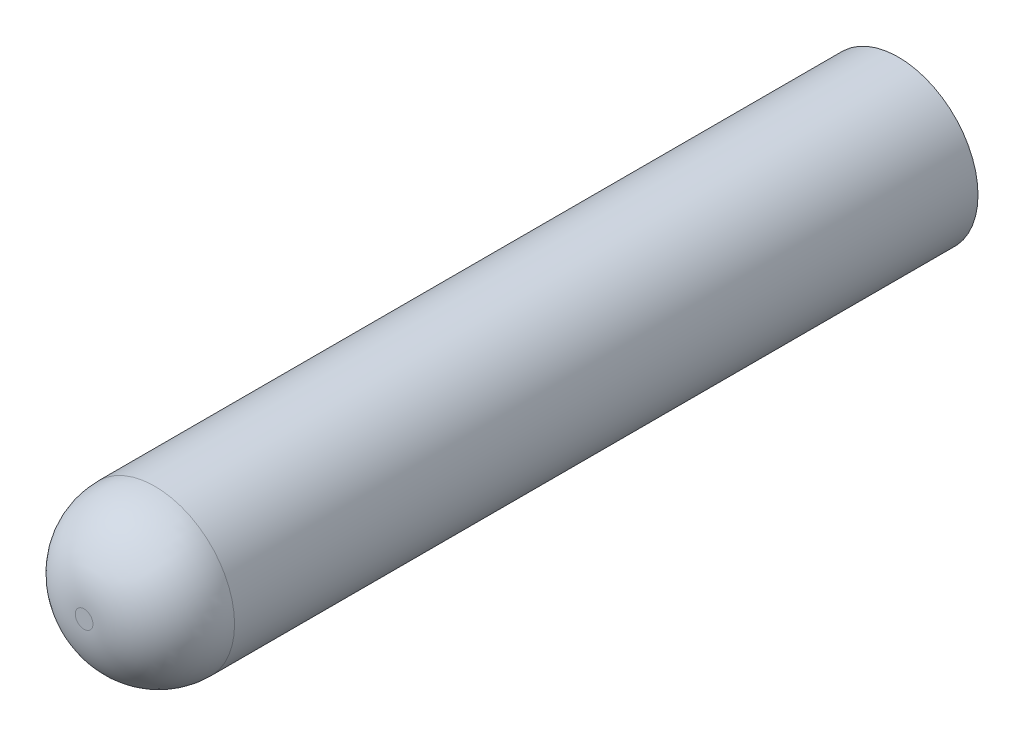
from build123d import *

# Parameters (mm, degrees)
SKETCH_1_R          = 2.25
EXTRUDE_2_DEPTH     = 23
SKETCH_7_W          = 2.35
SKETCH_7_H          = 2.35
CUT_EXTRUDE_3_DEPTH = 4.5
FILLET_2_R          = 2


with BuildPart() as part:
    # 草图1 → 凸台-拉伸2 (new body)
    with BuildSketch(Plane.XY):
        Circle(SKETCH_1_R)
    extrude(amount=EXTRUDE_2_DEPTH)

    # 草图7 → 切除-拉伸3 (cut)
    with BuildSketch(Plane.XY):
        Rectangle(SKETCH_7_W, SKETCH_7_H)
    extrude(amount=CUT_EXTRUDE_3_DEPTH, mode=Mode.SUBTRACT)

    # 圆角2
    fillet_2_edges = [part.edges().sort_by_distance(p)[0] for p in [
        (-2.25, 0, 23),
    ]]
    fillet(fillet_2_edges, radius=FILLET_2_R)


solid = part.part
